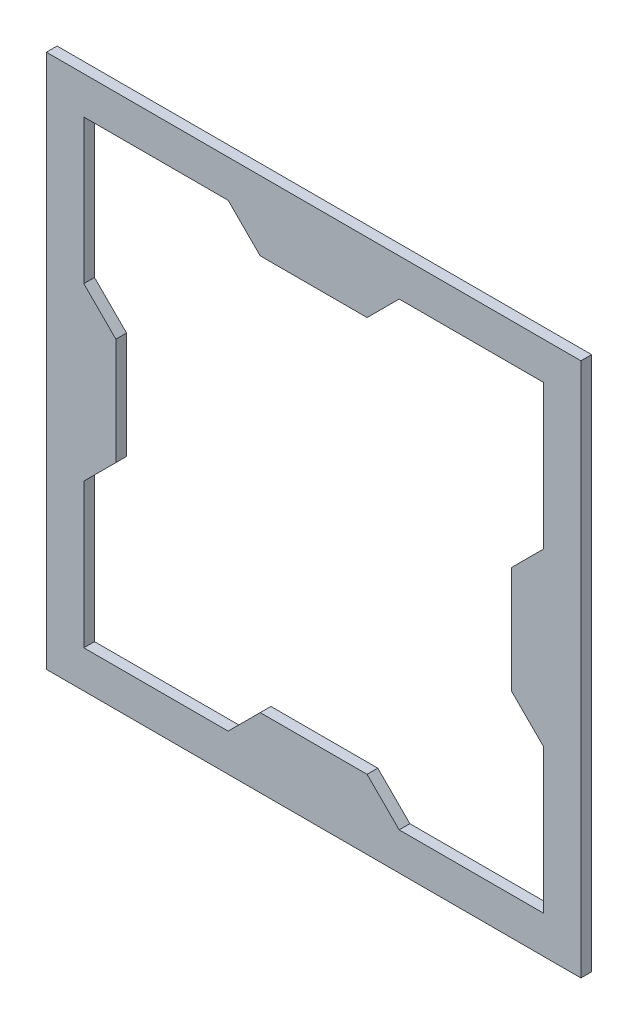
from build123d import *

# Parameters (mm, degrees)
SKETCH1_W           = 158.75
SKETCH1_H           = 158.75
SKETCH1_W_2         = 136.525
SKETCH1_H_2         = 136.525
BOSS_EXTRUDE1_DEPTH = 3.175


with BuildPart() as part:
    # Sketch1 → Boss-Extrude1 (new body)
    with BuildSketch(Plane.XY):
        Rectangle(SKETCH1_W, SKETCH1_H)
        Rectangle(SKETCH1_W_2, SKETCH1_H_2, mode=Mode.SUBTRACT)
        Polygon((25.4, 68.2625), (-25.4, 68.2625), (-15.875, 58.7375), (15.875, 58.7375), align=None)
        Polygon((68.2625, -25.4), (68.2625, 25.4), (58.7375, 15.875), (58.7375, -15.875), align=None)
        Polygon((-15.875, -58.7375), (-25.4, -68.2625), (25.4, -68.2625), (15.875, -58.7375), align=None)
        Polygon((-58.7375, 15.875), (-68.2625, 25.4), (-68.2625, -25.4), (-58.7375, -15.875), align=None)
    extrude(amount=BOSS_EXTRUDE1_DEPTH)


solid = part.part
